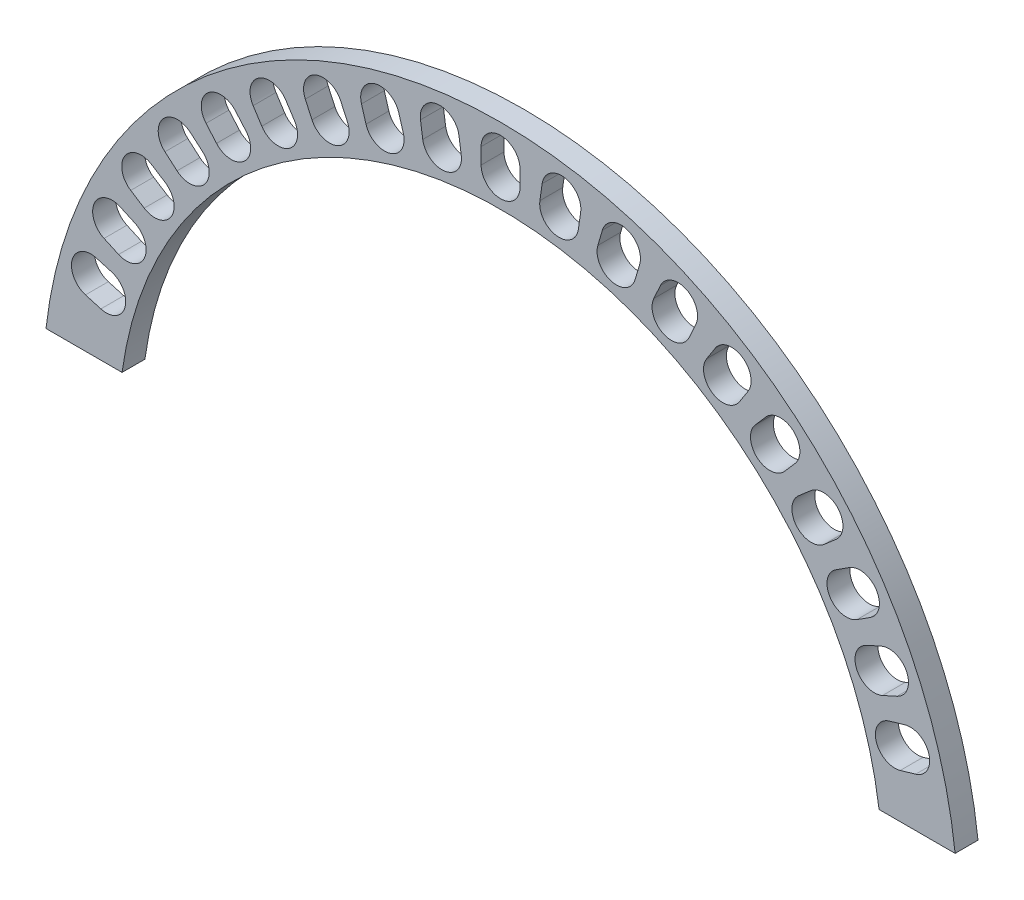
from build123d import *

# Parameters (mm, degrees)
BOSS_EXTRU_1_DEPTH           = 10
ENL_V_MAT_EXTRU_1_DEPTH      = 11
R_P_TITION_CIRCULAIRE1_COUNT = 10
R_P_TITION_CIRCULAIRE1_ANGLE = 73.8
R_P_TITION_CIRCULAIRE2_COUNT = 10
R_P_TITION_CIRCULAIRE2_ANGLE = 73.8


with BuildPart() as part:
    # Esquisse1 → Boss.-Extru.1 (new body)
    with BuildSketch(Plane.XY):
        with BuildLine():
            Line((-140.132008959, 22.5), (-106.879003857, 22.5))
            ThreePointArc((-106.879003857, 22.5), (58.598335981, 167), (224.07567582, 22.5))
            Line((224.07567582, 22.5), (257.328680921, 22.5))
            ThreePointArc((257.328680921, 22.5), (58.598335981, 200), (-140.132008959, 22.5))
        make_face()
    extrude(amount=BOSS_EXTRU_1_DEPTH)

    # Esquisse2 → Enlèv. mat.-Extru.1 (cut, through all)
    with BuildSketch(Plane.XY.offset(10)):
        with BuildLine():
            Line((50.098335981, 179.5), (50.098335981, 186.5))
            ThreePointArc((50.098335981, 186.5), (58.598335981, 195), (67.098335981, 186.5))
            Line((67.098335981, 186.5), (67.098335981, 179.5))
            ThreePointArc((67.098335981, 179.5), (58.598335981, 171), (50.098335981, 179.5))
        make_face()
    enl_v_mat_extru_1 = extrude(amount=-ENL_V_MAT_EXTRU_1_DEPTH, mode=Mode.SUBTRACT)

    # Répétition circulaire1: Enlèv. mat.-Extru.1 ×10 about axis
    r_p_tition_circulaire1_axis = Axis((58.598335981, 0, 0), (0, 0, -1))
    for i in range(1, R_P_TITION_CIRCULAIRE1_COUNT):
        add(enl_v_mat_extru_1.rotate(r_p_tition_circulaire1_axis, i * R_P_TITION_CIRCULAIRE1_ANGLE / (R_P_TITION_CIRCULAIRE1_COUNT - 1)), mode=Mode.SUBTRACT)

    # Répétition circulaire2: Enlèv. mat.-Extru.1 ×10 about axis
    r_p_tition_circulaire2_axis = Axis((58.598335981, 0, 0), (0, 0, 1))
    for i in range(1, R_P_TITION_CIRCULAIRE2_COUNT):
        add(enl_v_mat_extru_1.rotate(r_p_tition_circulaire2_axis, i * R_P_TITION_CIRCULAIRE2_ANGLE / (R_P_TITION_CIRCULAIRE2_COUNT - 1)), mode=Mode.SUBTRACT)


solid = part.part
